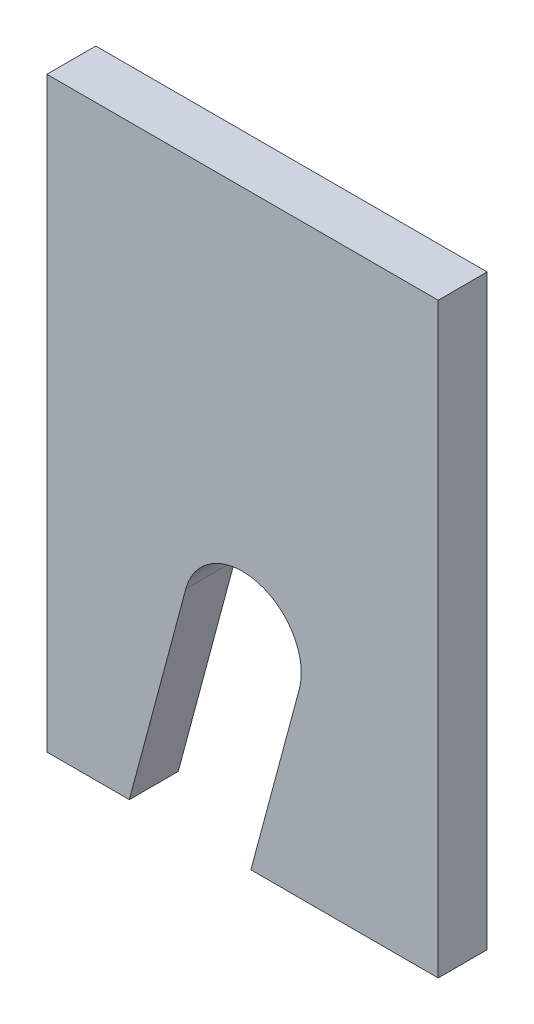
from build123d import *

# Parameters (mm, degrees)
BOSS_EXTRUDE1_DEPTH = 6.35


with BuildPart() as part:
    # Sketch1 → Boss-Extrude1 (new body)
    with BuildSketch(Plane.XY):
        with BuildLine():
            Line((10.705286018, 0), (18.039645204, 27.372201124))
            ThreePointArc((18.039645204, 27.372201124), (27.372201124, 32.760354796), (32.760354796, 23.427798876))
            Line((32.760354796, 23.427798876), (26.482895007, 0))
            Line((26.482895007, 0), (50.8, 0))
            Line((50.8, 0), (50.8, 76.2))
            Line((50.8, 76.2), (0, 76.2))
            Line((0, 76.2), (0, 0))
            Line((0, 0), (10.705286018, 0))
        make_face()
    extrude(amount=BOSS_EXTRUDE1_DEPTH)


solid = part.part
